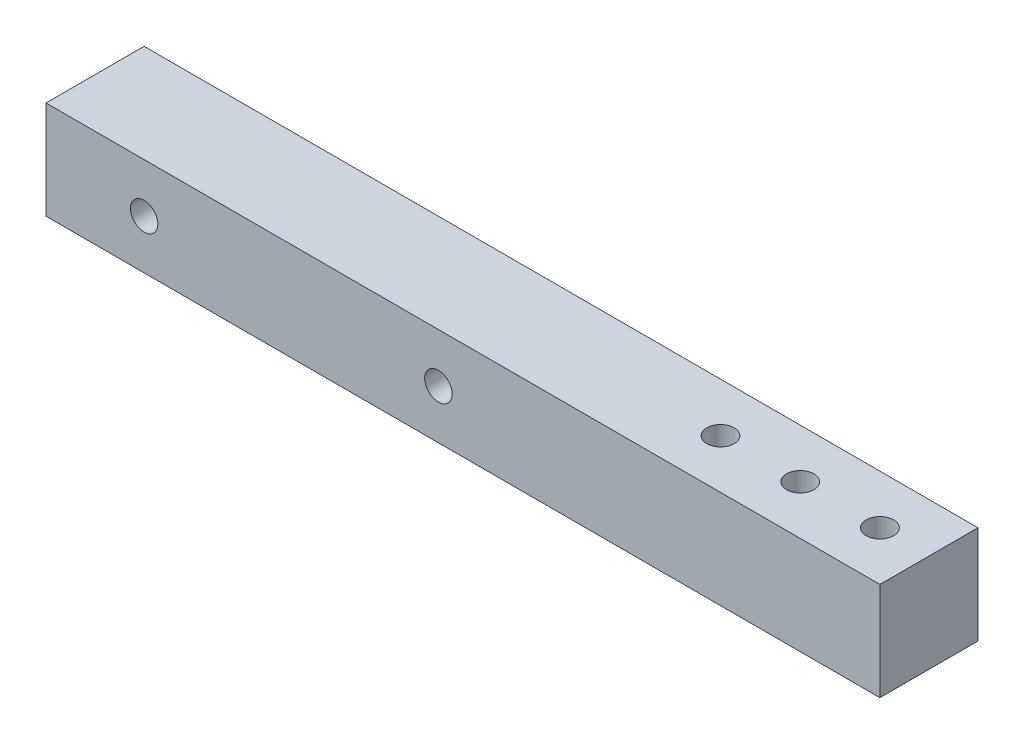
from build123d import *

# Parameters (mm, degrees)
SKETCH1_W           = 107.95
SKETCH1_H           = 12.7
BOSS_EXTRUDE1_DEPTH = 12.7
SKETCH2_R           = 1.778
CUT_EXTRUDE1_DEPTH  = 12.7
SKETCH3_R           = 1.778
CUT_EXTRUDE2_DEPTH  = 12.7
SKETCH4_R           = 1.778
CUT_EXTRUDE3_DEPTH  = 12.7


with BuildPart() as part:
    # Sketch1 → Boss-Extrude1 (new body)
    with BuildSketch(Plane.XY):
        with Locations((53.975, 6.35)):
            Rectangle(SKETCH1_W, SKETCH1_H)
    extrude(amount=BOSS_EXTRUDE1_DEPTH)

    # Sketch2 → Cut-Extrude1 (cut)
    with BuildSketch(Plane(origin=(0, 12.7, 0), x_dir=(1, 0, 0), z_dir=(0, 1, 0))):
        with Locations((101.6, -6.35)):
            Circle(SKETCH2_R)
        with Locations((80.9625, -6.35)):
            Circle(SKETCH2_R)
    extrude(amount=-CUT_EXTRUDE1_DEPTH, mode=Mode.SUBTRACT)

    # Sketch3 → Cut-Extrude2 (cut)
    with BuildSketch(Plane.XZ):
        with Locations((91.28125, 6.35)):
            Circle(SKETCH3_R)
    extrude(amount=-CUT_EXTRUDE2_DEPTH, mode=Mode.SUBTRACT)

    # Sketch4 → Cut-Extrude3 (cut)
    with BuildSketch(Plane(origin=(0, 0, 0), x_dir=(-1, 0, 0), z_dir=(0, 0, -1))):
        with Locations((-12.7, 6.35)):
            Circle(SKETCH4_R)
        with Locations((-50.8, 6.35)):
            Circle(SKETCH4_R)
    extrude(amount=-CUT_EXTRUDE3_DEPTH, mode=Mode.SUBTRACT)


solid = part.part
